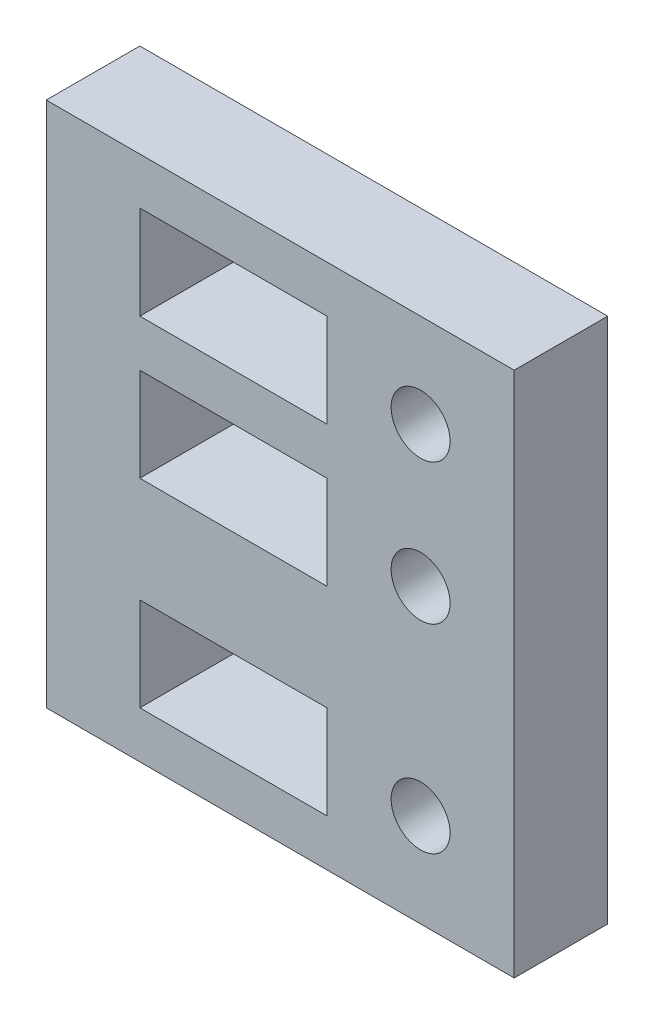
from build123d import *

# Parameters (mm, degrees)
SKETCH1_R           = 2
SKETCH1_W           = 12.7
SKETCH1_H           = 6.35
BOSS_EXTRUDE1_DEPTH = 6.35


with BuildPart() as part:
    # Sketch1 → Boss-Extrude1 (new body)
    with BuildSketch(Plane.XY):
        Polygon((0, 35.71875), (0, 26.19375), (0, 0), (31.75, 0), (31.75, 26.19375), (31.75, 35.71875), align=None)
        with Locations((25.4, 19.84375)):
            Circle(SKETCH1_R, mode=Mode.SUBTRACT)
        with Locations((25.4, 6.35)):
            Circle(SKETCH1_R, mode=Mode.SUBTRACT)
        with Locations((25.4, 29.36875)):
            Circle(SKETCH1_R, mode=Mode.SUBTRACT)
        with Locations((12.7, 19.84375)):
            Rectangle(SKETCH1_W, SKETCH1_H, mode=Mode.SUBTRACT)
        with Locations((12.7, 6.35)):
            Rectangle(SKETCH1_W, SKETCH1_H, mode=Mode.SUBTRACT)
        with Locations((12.7, 29.36875)):
            Rectangle(SKETCH1_W, SKETCH1_H, mode=Mode.SUBTRACT)
    extrude(amount=BOSS_EXTRUDE1_DEPTH)


solid = part.part
